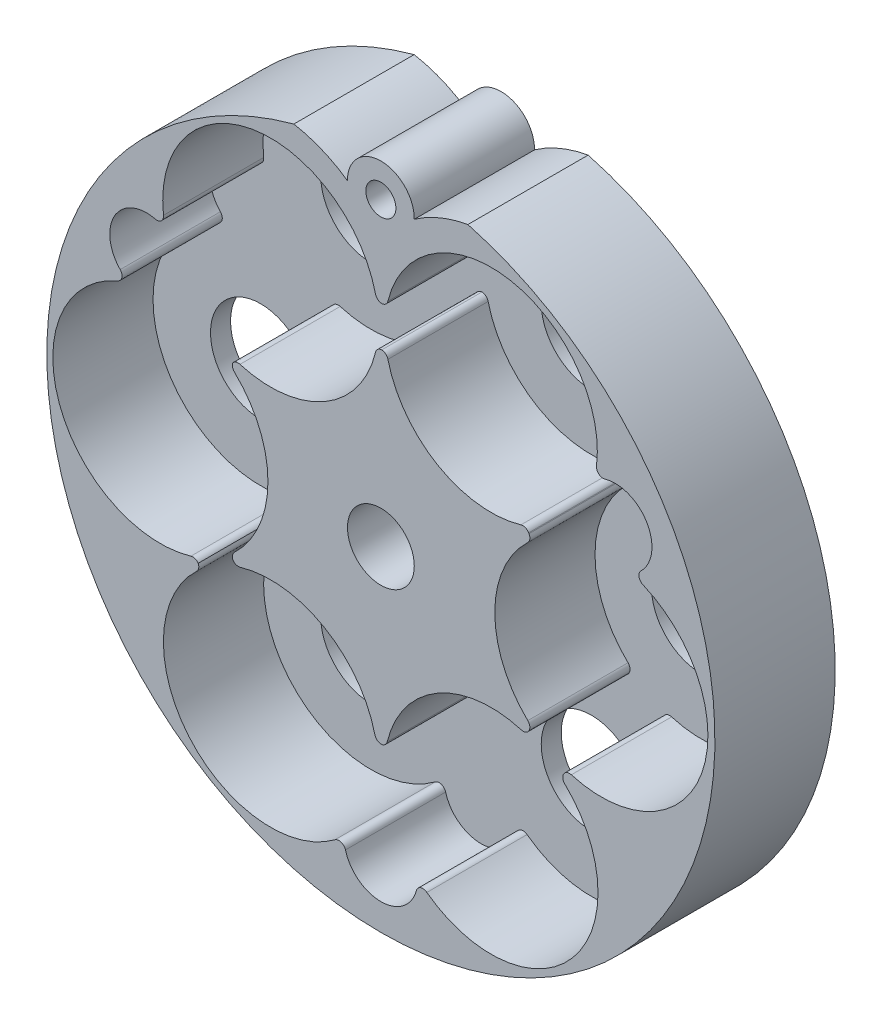
from build123d import *

# Parameters (mm, degrees)
EXTRUDE_1_DEPTH             = 18
CUT_EXTRUDE_1_DEPTH         = 15
EXTRUDE_2_DEPTH             = 15
HOLE_WIZARD_4_5_4_5_1_D     = 4.5
HOLE_WIZARD_4_5_4_5_1_DEPTH = 18
HOLE_WIZARD_10_0_10_1_D     = 10
HOLE_WIZARD_10_0_10_1_DEPTH = 18
HOLE_WIZARD_15_0_15_1_D     = 15
HOLE_WIZARD_15_0_15_1_DEPTH = 18
FILLET_1_R                  = 1


with BuildPart() as part:
    # 草图1 → 凸台-拉伸1 (new body)
    with BuildSketch(Plane(origin=(0, 0, 0), x_dir=(-1, 0, 0), z_dir=(0, 0, -1))):
        with BuildLine():
            ThreePointArc((-63.022889612, -268.325738264), (-50, -366.6), (-36.977110388, -268.325738264))
            ThreePointArc((-36.977110388, -268.325738264), (-41.171867667, -269.55111981), (-45.000340281, -271.658332659))
            ThreePointArc((-45.000340281, -271.658332659), (-50, -266.6), (-54.999659719, -271.658332659))
            ThreePointArc((-54.999659719, -271.658332659), (-58.828132333, -269.55111981), (-63.022889612, -268.325738264))
        make_face()
    extrude(amount=-EXTRUDE_1_DEPTH)

    # 草图2 → 切除-拉伸1 (cut)
    with BuildSketch(Plane.XY.offset(18)):
        with BuildLine():
            Line((76.956193034, -333.068180736), (77.765412233, -331.666571969))
            ThreePointArc((77.765412233, -331.666571969), (97.88324923, -322.335101774), (89.229210711, -301.916695402))
            ThreePointArc((89.229210711, -301.916695402), (88.637121061, -301.181657), (88.92041407, -300.281325574))
            ThreePointArc((88.92041407, -300.281325574), (89.825644155, -293.580135017), (83.548411657, -291.065826255))
            ThreePointArc((83.548411657, -291.065826255), (82.62171892, -290.865593126), (82.278658267, -289.981759362))
            ThreePointArc((82.278658267, -289.981759362), (69.366720715, -272.381727147), (51.051780987, -284.257848066))
            ThreePointArc((51.051780987, -284.257848066), (50.716834815, -284.792322878), (50.128600006, -285.01998946))
            ThreePointArc((50.128600006, -285.01998946), (49.538997539, -284.791191751), (49.204585003, -284.254397827))
            ThreePointArc((49.204585003, -284.254397827), (30.663154881, -272.122268325), (17.461812053, -289.918271942))
            ThreePointArc((17.461812053, -289.918271942), (17.131459448, -290.784603767), (16.231387053, -291.007164675))
            ThreePointArc((16.231387053, -291.007164675), (10.151561622, -293.619612904), (10.9830551, -300.184502973))
            ThreePointArc((10.9830551, -300.184502973), (11.246762281, -301.077699779), (10.659953012, -301.80088502))
            ThreePointArc((10.659953012, -301.80088502), (1.85480976, -322.061978817), (21.565140626, -332.039219251))
            ThreePointArc((21.565140626, -332.039219251), (22.17257693, -332.052081262), (22.660452123, -332.414189106))
            ThreePointArc((22.660452123, -332.414189106), (22.73017699, -333.017409123), (22.438041219, -333.549755475))
            ThreePointArc((22.438041219, -333.549755475), (21.244961438, -355.543032932), (43.131077631, -358.018030031))
            ThreePointArc((43.131077631, -358.018030031), (44.05505938, -357.871893349), (44.695584039, -358.553675105))
            ThreePointArc((44.695584039, -358.553675105), (50.022786366, -362.599952798), (55.316278846, -358.509673449))
            ThreePointArc((55.316278846, -358.509673449), (55.955599054, -357.821048903), (56.883882353, -357.966734219))
            ThreePointArc((56.883882353, -357.966734219), (78.956360747, -355.220704534), (76.956193034, -333.068180736))
        make_face()
    extrude(amount=-CUT_EXTRUDE_1_DEPTH, mode=Mode.SUBTRACT)

    # 草图3 → 凸台-拉伸2 (add)
    with BuildSketch(Plane.XY.offset(3)):
        with BuildLine():
            Line((71.709131996, -303.043642956), (72.56925981, -304.533428031))
            ThreePointArc((72.56925981, -304.533428031), (67.05, -316.6), (72.56925981, -328.666571969))
            Line((72.56925981, -328.666571969), (71.760040611, -330.068180736))
            ThreePointArc((71.760040611, -330.068180736), (58.841180082, -331.130974521), (50.949212572, -341.414132443))
            ThreePointArc((50.949212572, -341.414132443), (50.614490777, -341.949534813), (50.02571996, -342.177664826))
            ThreePointArc((50.02571996, -342.177664826), (49.436675631, -341.949308595), (49.102060561, -341.41344243))
            ThreePointArc((49.102060561, -341.41344243), (41.525, -331.279130594), (28.959898219, -329.78435958))
            ThreePointArc((28.959898219, -329.78435958), (28.35280487, -329.771183403), (27.865263445, -329.409189888))
            ThreePointArc((27.865263445, -329.409189888), (27.79560645, -328.805623655), (28.088185773, -328.273137379))
            ThreePointArc((28.088185773, -328.273137379), (33.1, -316.6), (28.088185773, -304.926862621))
            ThreePointArc((28.088185773, -304.926862621), (27.800926844, -304.419745345), (27.845189576, -303.838602992))
            ThreePointArc((27.845189576, -303.838602992), (28.326676887, -303.509594278), (28.909820681, -303.505113168))
            ThreePointArc((28.909820681, -303.505113168), (41.575, -302.007471946), (49.204585003, -291.787925524))
            ThreePointArc((49.204585003, -291.787925524), (49.538997539, -291.251131599), (50.128600006, -291.02233389))
            ThreePointArc((50.128600006, -291.02233389), (50.716834815, -291.250000473), (51.051780987, -291.784475285))
            ThreePointArc((51.051780987, -291.784475285), (58.890667579, -301.982109354), (71.709131996, -303.043642956))
        make_face()
    extrude(amount=EXTRUDE_2_DEPTH)

    # Ø4.5 (4.5) 直径孔1
    with Locations(Plane.XY.offset(18)):
        with Locations((50, -271.6)):
            Hole(HOLE_WIZARD_4_5_4_5_1_D / 2, depth=HOLE_WIZARD_4_5_4_5_1_DEPTH)

    # Ø10.0 (10) 直径孔1
    with Locations(Plane.XY.offset(18)):
        with Locations((50, -316.6)):
            Hole(HOLE_WIZARD_10_0_10_1_D / 2, depth=HOLE_WIZARD_10_0_10_1_DEPTH)

    # Ø15.0 (15) 直径孔1
    with Locations(Plane(origin=(0, 0, 0), x_dir=(-1, 0, 0), z_dir=(0, 0, -1))):
        with Locations((-33.5, -288.021161675), (-83, -316.6), (-66.5, -345.178838325), (-33.5, -345.178838325), (-66.5, -288.021161675), (-17, -316.6)):
            Hole(HOLE_WIZARD_15_0_15_1_D / 2, depth=HOLE_WIZARD_15_0_15_1_DEPTH)

    # 圆角1
    fillet_1_edges = [part.edges().sort_by_distance(p)[0] for p in [
        (77.765412233, -331.666571969, 10.5),
        (76.956193034, -333.068180736, 10.5),
        (71.760040611, -330.068180736, 10.5),
        (72.56925981, -328.666571969, 10.5),
        (72.56925981, -304.533428031, 10.5),
        (71.709131996, -303.043642956, 10.5),
    ]]
    fillet(fillet_1_edges, radius=FILLET_1_R)


solid = part.part
